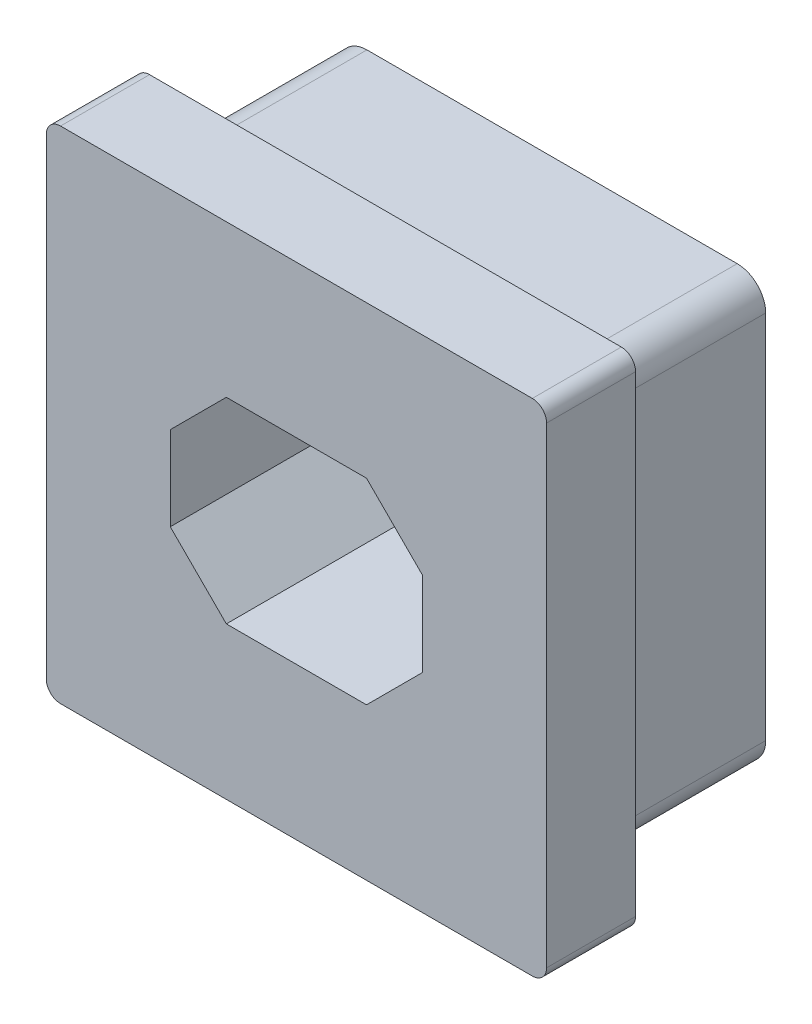
from build123d import *

# Parameters (mm, degrees)
BOSS_EXTRUDE1_DEPTH = 1.5875
SKETCH2_W           = 4.5
SKETCH2_H           = 3.5
CUT_EXTRUDE1_DEPTH  = 2.5875
CHAMFER1_SIZE       = 1
SKETCH3_W           = 7.62
SKETCH3_H           = 7.62
BOSS_EXTRUDE2_DEPTH = 2.9718
FILLET1_R           = 0.508


with BuildPart() as part:
    # Sketch1 → Boss-Extrude1 (new body)
    with BuildSketch(Plane.XY):
        with BuildLine():
            Line((4.207, 4.461), (-4.207, 4.461))
            ThreePointArc((-4.207, 4.461), (-4.386605122, 4.386605122), (-4.461, 4.207))
            Line((-4.461, 4.207), (-4.461, -4.207))
            ThreePointArc((-4.461, -4.207), (-4.386605122, -4.386605122), (-4.207, -4.461))
            Line((-4.207, -4.461), (4.207, -4.461))
            ThreePointArc((4.207, -4.461), (4.386605122, -4.386605122), (4.461, -4.207))
            Line((4.461, -4.207), (4.461, 4.207))
            ThreePointArc((4.461, 4.207), (4.386605122, 4.386605122), (4.207, 4.461))
        make_face()
    extrude(amount=BOSS_EXTRUDE1_DEPTH)

    # Sketch2 → Cut-Extrude1 (cut, through all)
    with BuildSketch(Plane.XY.offset(1.5875)):
        Rectangle(SKETCH2_W, SKETCH2_H)
    extrude(amount=-CUT_EXTRUDE1_DEPTH, mode=Mode.SUBTRACT)

    # Chamfer1
    chamfer1_edges = [part.edges().sort_by_distance(p)[0] for p in [
        (2.25, 1.75, 0.79375),
        (2.25, -1.75, 0.79375),
        (-2.25, -1.75, 0.79375),
        (-2.25, 1.75, 0.79375),
    ]]
    chamfer(chamfer1_edges, length=CHAMFER1_SIZE)

    # Sketch3 → Boss-Extrude2 (add)
    with BuildSketch(Plane(origin=(0, 0, 0), x_dir=(-1, 0, 0), z_dir=(0, 0, -1))):
        Rectangle(SKETCH3_W, SKETCH3_H)
        Polygon((2.25, -0.75), (2.25, 0.75), (1.25, 1.75), (-1.25, 1.75), (-2.25, 0.75), (-2.25, -0.75), (-1.25, -1.75), (1.25, -1.75), align=None, mode=Mode.SUBTRACT)
    extrude(amount=BOSS_EXTRUDE2_DEPTH)

    # Fillet1
    fillet1_edges = [part.edges().sort_by_distance(p)[0] for p in [
        (3.81, 3.81, -1.4859),
        (3.81, -3.81, -1.4859),
        (-3.81, -3.81, -1.4859),
        (-3.81, 3.81, -1.4859),
    ]]
    fillet(fillet1_edges, radius=FILLET1_R)


solid = part.part
